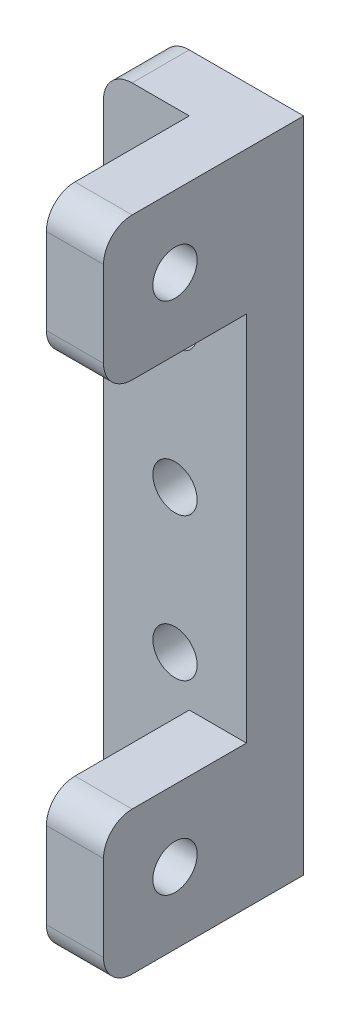
from build123d import *

# Parameters (mm, degrees)
SKETCH1_W           = 10
SKETCH1_H           = 46
SKETCH1_R           = 1.55
BOSS_EXTRUDE1_DEPTH = 4
SKETCH2_W           = 4
SKETCH2_H           = 10
BOSS_EXTRUDE2_DEPTH = 10
CUT_EXTRUDE1_REACH  = 6
SKETCH3_R           = 1.55
FILLET1_R           = 2


with BuildPart() as part:
    # Sketch1 → Boss-Extrude1 (new body)
    with BuildSketch(Plane.XY):
        Rectangle(SKETCH1_W, SKETCH1_H)
        with Locations((0, 10)):
            Circle(SKETCH1_R, mode=Mode.SUBTRACT)
        Circle(SKETCH1_R, mode=Mode.SUBTRACT)
        with Locations((0, -10)):
            Circle(SKETCH1_R, mode=Mode.SUBTRACT)
    extrude(amount=BOSS_EXTRUDE1_DEPTH)

    # Sketch2 → Boss-Extrude2 (add)
    with BuildSketch(Plane.XY.offset(4)):
        with Locations((3, 18)):
            Rectangle(SKETCH2_W, SKETCH2_H)
        with Locations((3, -18)):
            Rectangle(SKETCH2_W, SKETCH2_H)
    extrude(amount=BOSS_EXTRUDE2_DEPTH)

    # Sketch3 → Cut-Extrude1 (cut, up to next)
    with BuildSketch(Plane.ZY.offset(-1), mode=Mode.PRIVATE) as cut_extrude1_sk1:
        with Locations((9, 18)):
            Circle(SKETCH3_R)
    cut_extrude1_tool1 = extrude(cut_extrude1_sk1.sketch, amount=-CUT_EXTRUDE1_REACH, mode=Mode.PRIVATE) & part.part
    add(cut_extrude1_tool1.solids().sort_by_distance((1, 18, 9))[0], mode=Mode.SUBTRACT)
    # Sketch3 → Cut-Extrude1 (cut, up to next)
    with BuildSketch(Plane.ZY.offset(-1), mode=Mode.PRIVATE) as cut_extrude1_sk2:
        with Locations((9, -18)):
            Circle(SKETCH3_R)
    cut_extrude1_tool2 = extrude(cut_extrude1_sk2.sketch, amount=-CUT_EXTRUDE1_REACH, mode=Mode.PRIVATE) & part.part
    add(cut_extrude1_tool2.solids().sort_by_distance((1, -18, 9))[0], mode=Mode.SUBTRACT)

    # Fillet1
    fillet1_edges = [part.edges().sort_by_distance(p)[0] for p in [
        (3, 23, 14),
        (3, 13, 14),
        (3, -13, 14),
        (3, -23, 14),
        (-5, -23, 2),
        (-5, 23, 2),
    ]]
    fillet(fillet1_edges, radius=FILLET1_R)


solid = part.part
